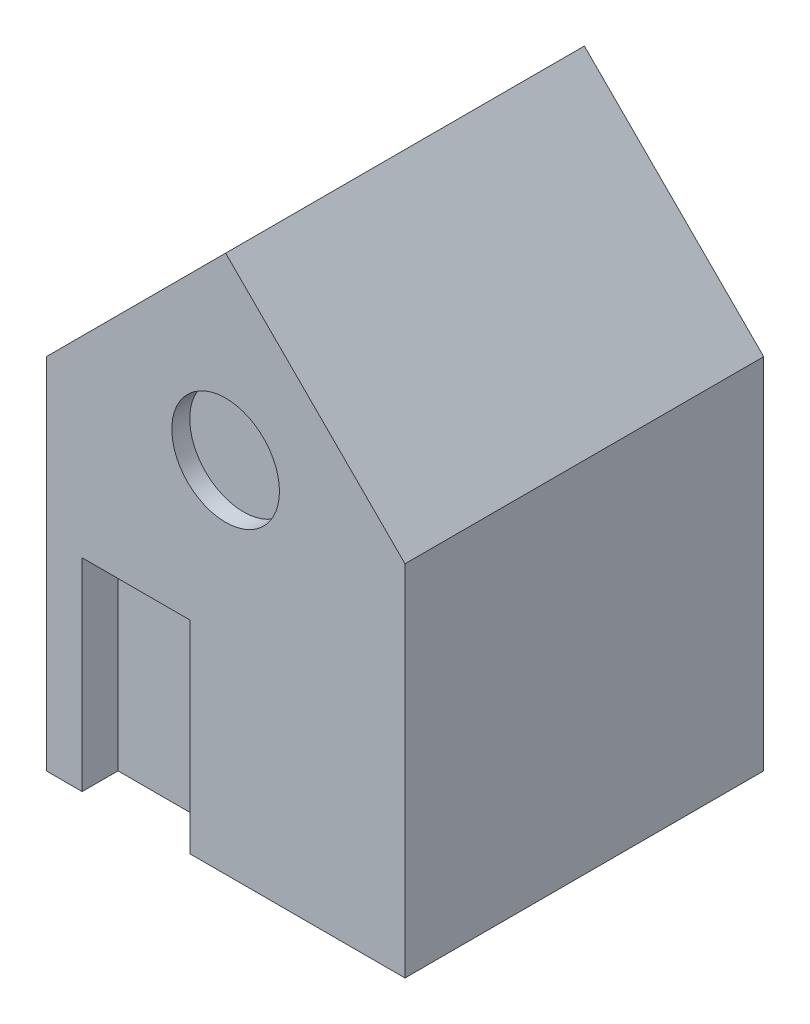
from build123d import *

# Parameters (mm, degrees)
BOSS_EXTRUDE1_DEPTH = 50
SKETCH2_W           = 30
SKETCH2_H           = 56.451302081
CUT_EXTRUDE1_DEPTH  = 10
SKETCH3_R           = 15
CUT_EXTRUDE2_DEPTH  = 5


with BuildPart() as part:
    # Sketch1 → Boss-Extrude1 (new body, symmetric)
    with BuildSketch(Plane.XY):
        Polygon((-50, 0), (50, 0), (50, 100), (0, 150), (-50, 100), align=None)
    extrude(amount=BOSS_EXTRUDE1_DEPTH, both=True)

    # Sketch2 → Cut-Extrude1 (cut)
    with BuildSketch(Plane.XY.offset(50)):
        with Locations((-25, 28.225651041)):
            Rectangle(SKETCH2_W, SKETCH2_H)
    extrude(amount=-CUT_EXTRUDE1_DEPTH, mode=Mode.SUBTRACT)

    # Sketch3 → Cut-Extrude2 (cut)
    with BuildSketch(Plane.XY.offset(50)):
        with Locations((0, 100)):
            Circle(SKETCH3_R)
    extrude(amount=-CUT_EXTRUDE2_DEPTH, mode=Mode.SUBTRACT)


solid = part.part
